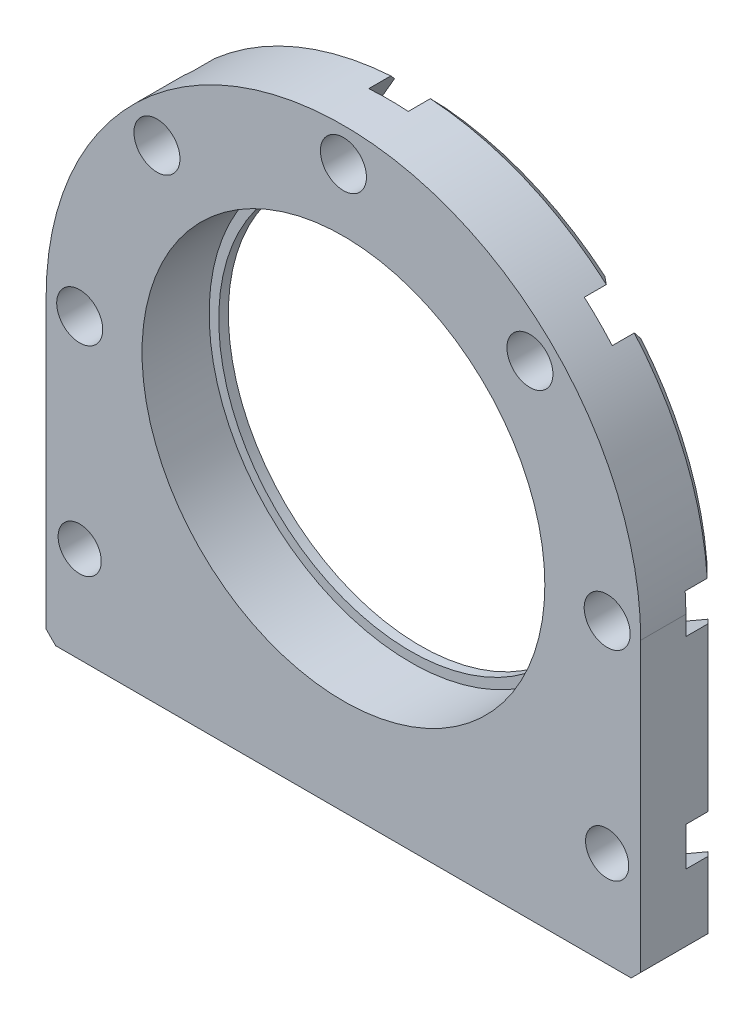
from build123d import *

# Parameters (mm, degrees)
EXTRUDE_1_DEPTH          = 8
HOLE_WIZARD_M4_1_D       = 4.8
PATTERN_CIRCULAR_1_COUNT = 8
CHAMFER_1_SIZE           = 1
CUT_EXTRUDE_2_DEPTH      = 3.3
PATTERN_CIRCULAR_3_COUNT = 8
SKETCH_7_R               = 21
CUT_EXTRUDE_4_DEPTH      = 7
SKETCH_8_R               = 20
CUT_EXTRUDE_5_DEPTH      = 45.395945761
HOLE_WIZARD_M4_2_D       = 4.5
CUT_EXTRUDE_6_DEPTH      = 3.3


with BuildPart() as part:
    # ｽｹｯﾁ1 → ﾎﾞｽ - 押し出し1 (new body)
    with BuildSketch(Plane.XY):
        with BuildLine():
            Line((31, -31), (-31, -31))
            Line((-31, -31), (-31, 0))
            ThreePointArc((-31, 0), (0, 31), (31, 0))
            Line((31, 0), (31, -31))
        make_face()
    extrude(amount=EXTRUDE_1_DEPTH)

    # M4 すきま穴1 (through all)
    with Locations(Plane(origin=(0, 0, 0), x_dir=(1, 0, 0), z_dir=(0, 0, -1))):
        with Locations((0, -27.5)):
            hole_wizard_m4_1 = Hole(HOLE_WIZARD_M4_1_D / 2)

    # 円形ﾊﾟﾀｰﾝ1: M4 すきま穴1 ×8 about axis, 3 skipped
    pattern_circular_1_axis = Axis((0, 0, 0), (0, 0, -1))
    add([hole_wizard_m4_1.rotate(pattern_circular_1_axis, i * 360 / PATTERN_CIRCULAR_1_COUNT) for i in range(1, PATTERN_CIRCULAR_1_COUNT) if i not in (3, 4, 5)], mode=Mode.SUBTRACT)

    # 面取り1
    chamfer_1_edges = [part.edges().sort_by_distance(p)[0] for p in [
        (31, -15.5, 0),
        (0, -31, 0),
        (-31, -15.5, 0),
        (0, 31, 0),
        (31, -31, 4),
        (-31, -31, 4),
    ]]
    chamfer(chamfer_1_edges, length=CHAMFER_1_SIZE)

    # ｽｹｯﾁ5 → ｶｯﾄ - 押し出し2 (cut)
    with BuildSketch(Plane(origin=(0, 0, 0), x_dir=(-1, 0, 0), z_dir=(0, 0, -1))):
        Polygon((2.020725942, 24), (4.041451884, 27.5), (2.020725942, 31), (-2.020725942, 31), (-4.041451884, 27.5), (-2.020725942, 24), align=None)
    cut_extrude_2 = extrude(amount=-CUT_EXTRUDE_2_DEPTH, mode=Mode.SUBTRACT)

    # 円形ﾊﾟﾀｰﾝ3: ｶｯﾄ - 押し出し2 ×8 about axis, 3 skipped
    pattern_circular_3_axis = Axis((0, 0, 0), (0, 0, -1))
    add([cut_extrude_2.rotate(pattern_circular_3_axis, i * 360 / PATTERN_CIRCULAR_3_COUNT) for i in range(1, PATTERN_CIRCULAR_3_COUNT) if i not in (3, 4, 5)], mode=Mode.SUBTRACT)

    # ｽｹｯﾁ7 → ｶｯﾄ - 押し出し4 (cut)
    with BuildSketch(Plane.XY.offset(8)):
        Circle(SKETCH_7_R)
    extrude(amount=-CUT_EXTRUDE_4_DEPTH, mode=Mode.SUBTRACT)

    # ｽｹｯﾁ8 → ｶｯﾄ - 押し出し5 (cut, through all)
    with BuildSketch(Plane.XY.offset(1)):
        Circle(SKETCH_8_R)
    extrude(amount=-CUT_EXTRUDE_5_DEPTH, mode=Mode.SUBTRACT)

    # M4 すきま穴2 (through all)
    with Locations(Plane(origin=(0, 0, 0), x_dir=(-1, 0, 0), z_dir=(0, 0, -1))):
        with Locations((-27.5, -21), (27.5, -21)):
            Hole(HOLE_WIZARD_M4_2_D / 2)

    # ｽｹｯﾁ11 → ｶｯﾄ - 押し出し6 (cut)
    with BuildSketch(Plane(origin=(0, 0, 0), x_dir=(-1, 0, 0), z_dir=(0, 0, -1))):
        Polygon((-24, -23.020725942), (-24, -18.979274058), (-27.5, -16.958548116), (-31, -18.979274058), (-31, -23.020725942), (-27.5, -25.041451884), align=None)
        Polygon((27.5, -25.041451884), (31, -23.020725942), (31, -18.979274058), (27.5, -16.958548116), (24, -18.979274058), (24, -23.020725942), align=None)
    extrude(amount=-CUT_EXTRUDE_6_DEPTH, mode=Mode.SUBTRACT)


solid = part.part
